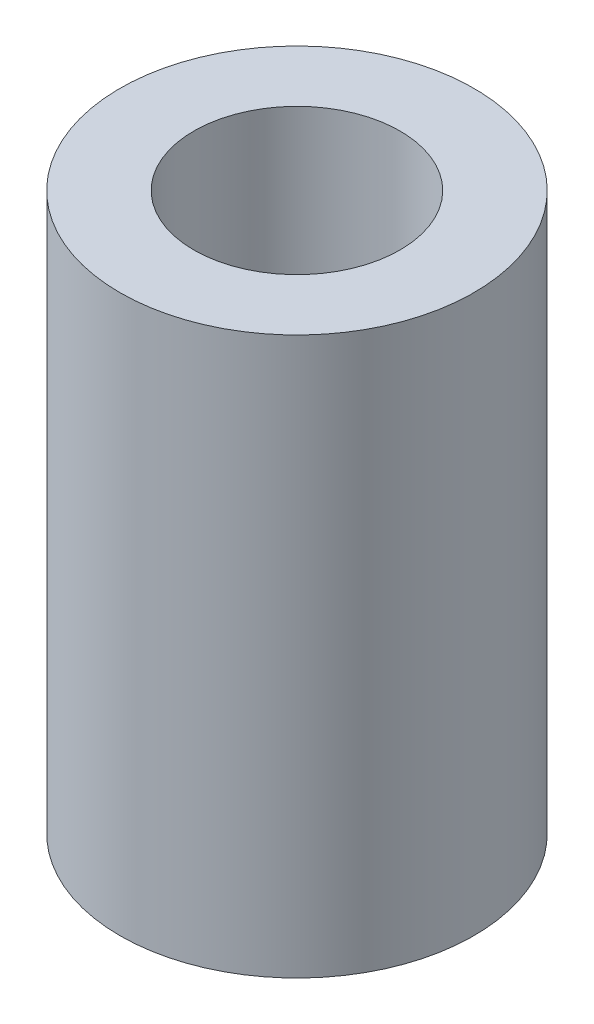
from build123d import *

# Parameters (mm, degrees)
PROFILE_SKETCH_R      = 7.1501
PROFILE_SKETCH_R_2    = 4.1656
PROFILE_EXTRUDE_DEPTH = 22.5


with BuildPart() as part:
    # Profile Sketch → Profile Extrude (new body)
    with BuildSketch(Plane(origin=(0, 0, 0), x_dir=(1, 0, 0), z_dir=(0, 1, 0))):
        Circle(PROFILE_SKETCH_R)
        Circle(PROFILE_SKETCH_R_2, mode=Mode.SUBTRACT)
    extrude(amount=PROFILE_EXTRUDE_DEPTH)


solid = part.part
